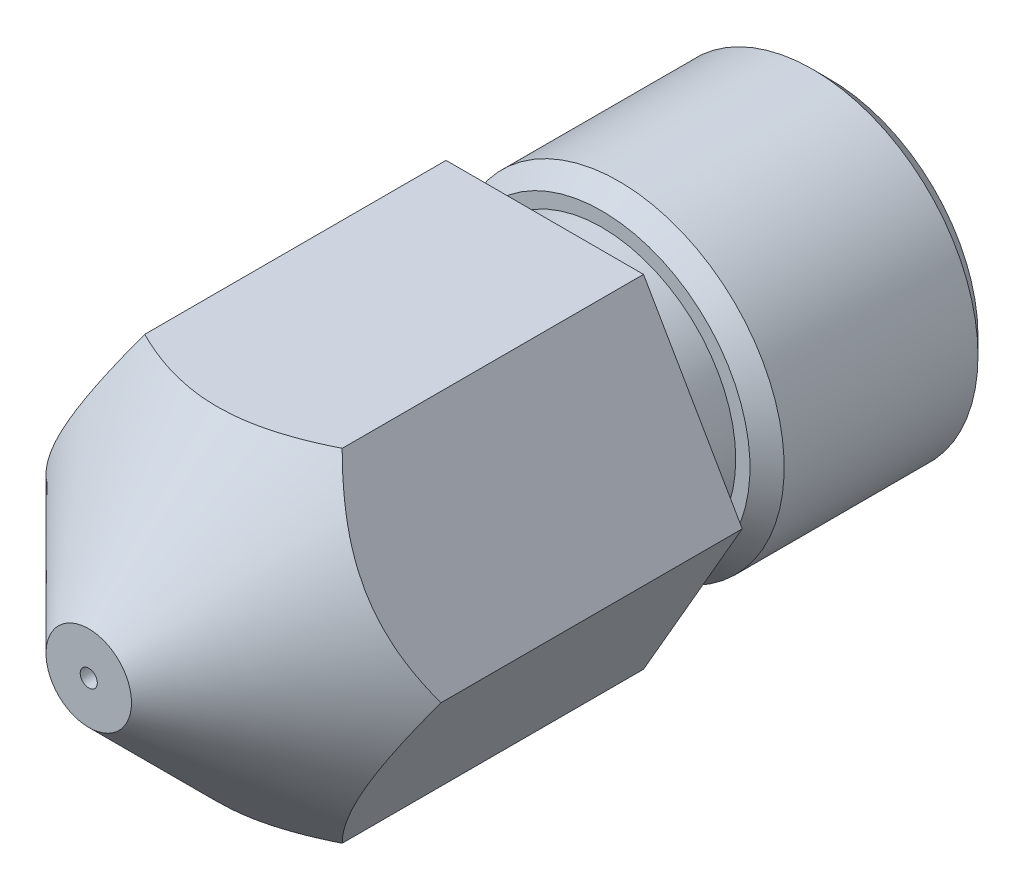
from build123d import *

# Parameters (mm, degrees)
EXTRUDE_1_DEPTH     = 13
SKETCH_2_OUTSIDE_W  = 38.11
SKETCH_2_OUTSIDE_H  = 37.182
SKETCH_2_OUTSIDE_R  = 0.75
CUT_EXTRUDE_1_DEPTH = 13
CUT_EXTRUDE_1_TAPER = 45
SKETCH_3_OUTSIDE_W  = 12.11
SKETCH_3_OUTSIDE_H  = 11.182
SKETCH_3_OUTSIDE_R  = 2.35
CUT_EXTRUDE_2_DEPTH = 5
SKETCH_4_R          = 1
CUT_EXTRUDE_3_DEPTH = 12
SKETCH_5_R          = 0.15
CUT_EXTRUDE_4_DEPTH = 1
SKETCH_6_R          = 2.9
SKETCH_6_R_2        = 2.35
EXTRUDE_2_DEPTH     = 4
CHAMFER_1_SIZE      = 0.3


with BuildPart() as part:
    # Эскиз1 → Бобышка-Вытянуть1 (new body)
    with BuildSketch(Plane.XY):
        Polygon((3.464101615, 0), (1.732050808, 3), (-1.732050808, 3), (-3.464101615, 0), (-1.732050808, -3), (1.732050808, -3), align=None)
    extrude(amount=EXTRUDE_1_DEPTH)

    # Эскиз2 outside → Вырез-Вытянуть1 (cut)
    with BuildSketch(Plane.XY.offset(13)):
        Rectangle(SKETCH_2_OUTSIDE_W, SKETCH_2_OUTSIDE_H)
        Circle(SKETCH_2_OUTSIDE_R, mode=Mode.SUBTRACT)
    extrude(amount=-CUT_EXTRUDE_1_DEPTH, taper=CUT_EXTRUDE_1_TAPER, mode=Mode.SUBTRACT)

    # Эскиз3 outside → Вырез-Вытянуть2 (cut)
    with BuildSketch(Plane(origin=(0, 0, 0), x_dir=(-1, 0, 0), z_dir=(0, 0, -1))):
        Rectangle(SKETCH_3_OUTSIDE_W, SKETCH_3_OUTSIDE_H)
        Circle(SKETCH_3_OUTSIDE_R, mode=Mode.SUBTRACT)
    extrude(amount=-CUT_EXTRUDE_2_DEPTH, mode=Mode.SUBTRACT)

    # Эскиз4 → Вырез-Вытянуть3 (cut)
    with BuildSketch(Plane(origin=(0, 0, 0), x_dir=(-1, 0, 0), z_dir=(0, 0, -1))):
        Circle(SKETCH_4_R)
    extrude(amount=-CUT_EXTRUDE_3_DEPTH, mode=Mode.SUBTRACT)

    # Эскиз5 → Вырез-Вытянуть4 (cut)
    with BuildSketch(Plane.XY.offset(13)):
        Circle(SKETCH_5_R)
    extrude(amount=-CUT_EXTRUDE_4_DEPTH, mode=Mode.SUBTRACT)

    # Эскиз6 → Бобышка-Вытянуть2 (add)
    with BuildSketch(Plane(origin=(0, 0, 0), x_dir=(-1, 0, 0), z_dir=(0, 0, -1))):
        Circle(SKETCH_6_R)
        Circle(SKETCH_6_R_2, mode=Mode.SUBTRACT)
    extrude(amount=-EXTRUDE_2_DEPTH)

    # Фаска1
    chamfer_1_edges = [part.edges().sort_by_distance(p)[0] for p in [
        (1, 0, 0),
        (2.9, 0, 4),
        (2.9, 0, 0),
    ]]
    chamfer(chamfer_1_edges, length=CHAMFER_1_SIZE)


solid = part.part
